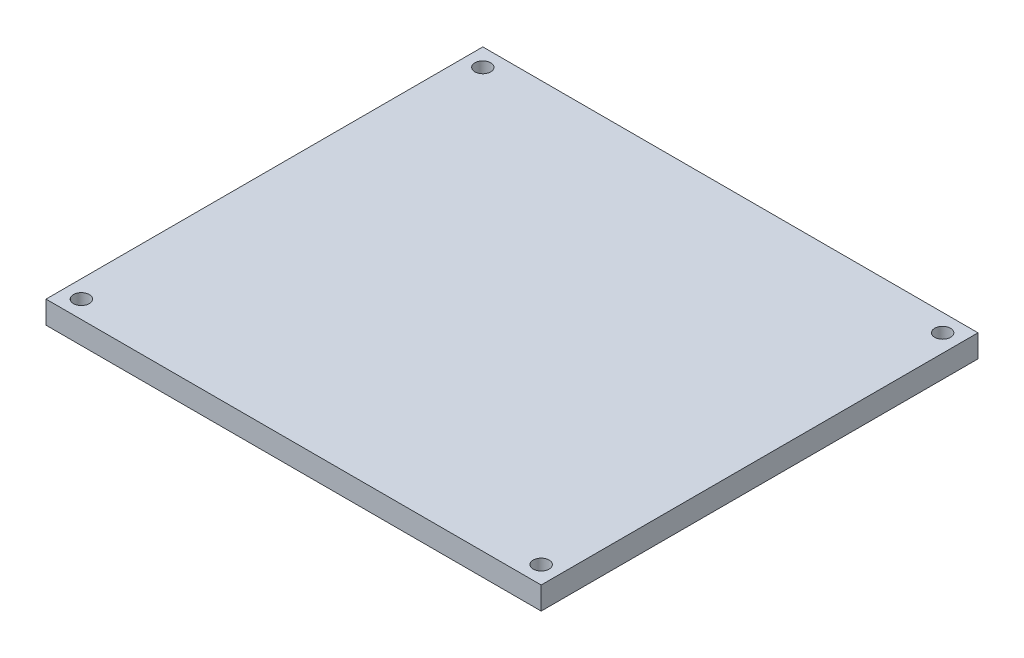
from build123d import *

# Parameters (mm, degrees)
GREENRECT_SKETCH_W      = 109.45
GREENRECT_SKETCH_H      = 96.55
GREENRECT_EXTRUDE_DEPTH = 5
SKETCH1_R               = 1.75
CUT_EXTRUDE1_DEPTH      = 6


with BuildPart() as part:
    # GreenRect Sketch → GreenRect Extrude (new body)
    with BuildSketch(Plane(origin=(0, 0, 0), x_dir=(1, 0, 0), z_dir=(0, 1, 0))):
        with Locations((54.725, 48.275)):
            Rectangle(GREENRECT_SKETCH_W, GREENRECT_SKETCH_H)
    extrude(amount=GREENRECT_EXTRUDE_DEPTH)

    # Sketch1 → Cut-Extrude1 (cut, through all)
    with BuildSketch(Plane(origin=(0, 5, 0), x_dir=(1, 0, 0), z_dir=(0, 1, 0))):
        with Locations((3.91, 92.64)):
            Circle(SKETCH1_R)
        with Locations((3.91, 3.91)):
            Circle(SKETCH1_R)
        with Locations((105.54, 3.91)):
            Circle(SKETCH1_R)
        with Locations((105.54, 92.64)):
            Circle(SKETCH1_R)
    extrude(amount=-CUT_EXTRUDE1_DEPTH, mode=Mode.SUBTRACT)


solid = part.part
